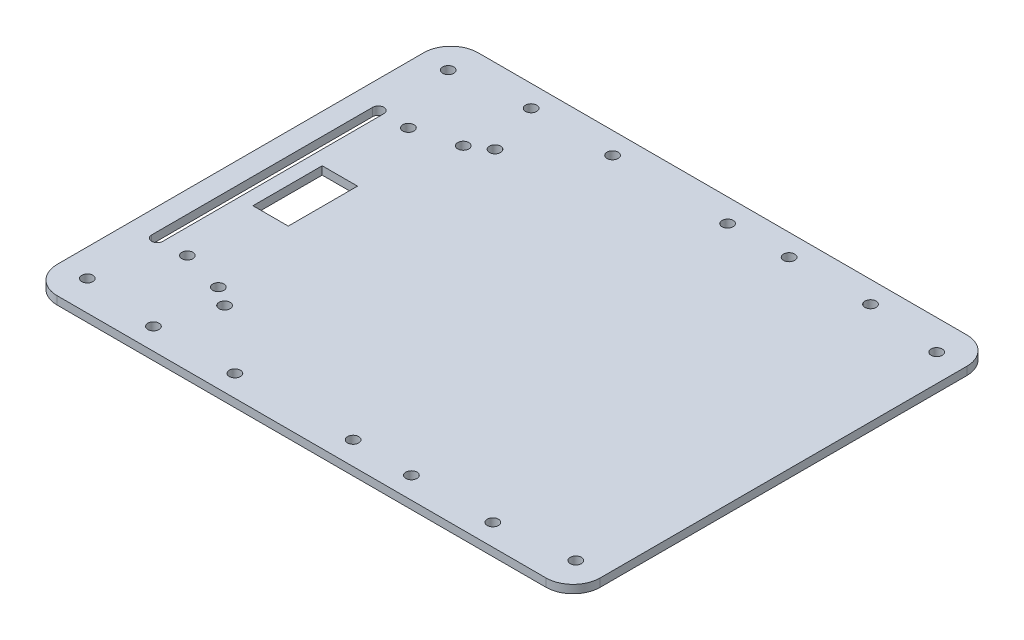
from build123d import *

# Parameters (mm, degrees)
SKETCH1_W           = 200
SKETCH1_H           = 155
BOSS_EXTRUDE1_DEPTH = 3
SKETCH2_R           = 2.05
CUT_EXTRUDE1_DEPTH  = 4
FILLET1_R           = 10
SKETCH6_R           = 2.05
SKETCH6_W           = 13
SKETCH6_H           = 25.5
CUT_EXTRUDE2_DEPTH  = 4


with BuildPart() as part:
    # Sketch1 → Boss-Extrude1 (new body)
    with BuildSketch(Plane(origin=(0, 0, 0), x_dir=(1, 0, 0), z_dir=(0, 1, 0))):
        with Locations((100, 77.5)):
            Rectangle(SKETCH1_W, SKETCH1_H)
    extrude(amount=BOSS_EXTRUDE1_DEPTH)

    # Sketch2 → Cut-Extrude1 (cut, through all)
    with BuildSketch(Plane(origin=(0, 3, 0), x_dir=(1, 0, 0), z_dir=(0, 1, 0))):
        with Locations((37.5, 7.95)):
            Circle(SKETCH2_R)
        with Locations((67.5, 7.95)):
            Circle(SKETCH2_R)
        with Locations((132.5, 7.95)):
            Circle(SKETCH2_R)
        with Locations((162.5, 7.95)):
            Circle(SKETCH2_R)
        with Locations((162.5, 147.05)):
            Circle(SKETCH2_R)
        with Locations((132.5, 147.05)):
            Circle(SKETCH2_R)
        with Locations((67.5, 147.05)):
            Circle(SKETCH2_R)
        with Locations((37.5, 147.05)):
            Circle(SKETCH2_R)
    extrude(amount=-CUT_EXTRUDE1_DEPTH, mode=Mode.SUBTRACT)

    # Fillet1
    fillet1_edges = [part.edges().sort_by_distance(p)[0] for p in [
        (0, 1.5, -155),
        (200, 1.5, -155),
        (200, 1.5, 0),
        (0, 1.5, 0),
    ]]
    fillet(fillet1_edges, radius=FILLET1_R)

    # Sketch6 → Cut-Extrude2 (cut, through all)
    with BuildSketch(Plane(origin=(0, 3, 0), x_dir=(1, 0, 0), z_dir=(0, 1, 0))):
        with Locations((10.05, 143.95)):
            Circle(SKETCH6_R)
        with Locations((21.15, 118.2)):
            Circle(SKETCH6_R)
        with Locations((36.95, 122.6)):
            Circle(SKETCH6_R)
        with Locations((43.95, 127.3)):
            Circle(SKETCH6_R)
        with Locations((43.95, 27.7)):
            Circle(SKETCH6_R)
        with Locations((36.95, 32.4)):
            Circle(SKETCH6_R)
        with Locations((10.05, 11.05)):
            Circle(SKETCH6_R)
        with Locations((21.15, 36.8)):
            Circle(SKETCH6_R)
        with Locations((189.95, 143.95)):
            Circle(SKETCH6_R)
        with Locations((110.45, 146.45)):
            Circle(SKETCH6_R)
        with Locations((189.95, 11.05)):
            Circle(SKETCH6_R)
        with Locations((110.45, 8.55)):
            Circle(SKETCH6_R)
        with BuildLine():
            Line((12.1, 118.2), (12.1, 36.8))
            ThreePointArc((12.1, 36.8), (10.05, 34.75), (8, 36.8))
            Line((8, 36.8), (8, 118.2))
            ThreePointArc((8, 118.2), (10.05, 120.25), (12.1, 118.2))
        make_face()
        with Locations((23.85, 77.5)):
            Rectangle(SKETCH6_W, SKETCH6_H)
    extrude(amount=-CUT_EXTRUDE2_DEPTH, mode=Mode.SUBTRACT)


solid = part.part
